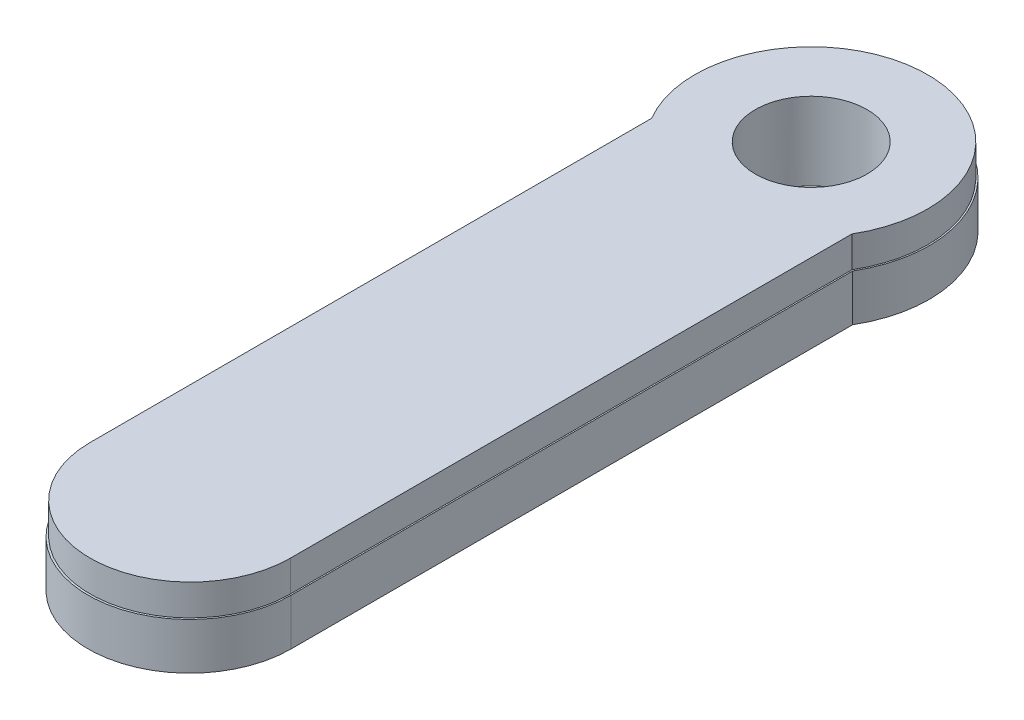
from build123d import *

# Parameters (mm, degrees)
EXTRUDE_1_DEPTH = 3
SKETCH_2_R      = 3.6
EXTRUDE_2_DEPTH = 2


with BuildPart() as part:
    # 草圖1 → 填料-伸長1 (new body)
    with BuildSketch(Plane(origin=(0, 0, 0), x_dir=(1, 0, 0), z_dir=(0, 1, 0))):
        with BuildLine():
            Line((-6.54186917, -3.868326222), (-6.54186917, -40.044486982))
            ThreePointArc((-6.54186917, -40.044486982), (0, -46.586356152), (6.54186917, -40.044486982))
            Line((6.54186917, -40.044486982), (6.54186917, -3.868326222))
            ThreePointArc((6.54186917, -3.868326222), (0, 7.6), (-6.54186917, -3.868326222))
        make_face()
        with BuildLine():
            Line((-2.6, -2.48997992), (-2.05, -14.677576073))
            ThreePointArc((-2.05, -14.677576073), (0, -16.637150357), (2.05, -14.677576073))
            Line((2.05, -14.677576073), (2.6, -2.48997992))
            ThreePointArc((2.6, -2.48997992), (0, 3.6), (-2.6, -2.48997992))
        make_face(mode=Mode.SUBTRACT)
    extrude(amount=EXTRUDE_1_DEPTH)

    # 草圖2 → 填料-伸長2 (add)
    with BuildSketch(Plane(origin=(0, 3, 0), x_dir=(1, 0, 0), z_dir=(0, 1, 0))):
        with BuildLine():
            Line((-6.451996083, -3.823839241), (-6.451996083, -40))
            ThreePointArc((-6.451996083, -40), (0, -46.451996083), (6.451996083, -40))
            Line((6.451996083, -40), (6.451996083, -3.823839241))
            ThreePointArc((6.451996083, -3.823839241), (0, 7.5), (-6.451996083, -3.823839241))
        make_face()
        Circle(SKETCH_2_R, mode=Mode.SUBTRACT)
    extrude(amount=EXTRUDE_2_DEPTH)


solid = part.part
